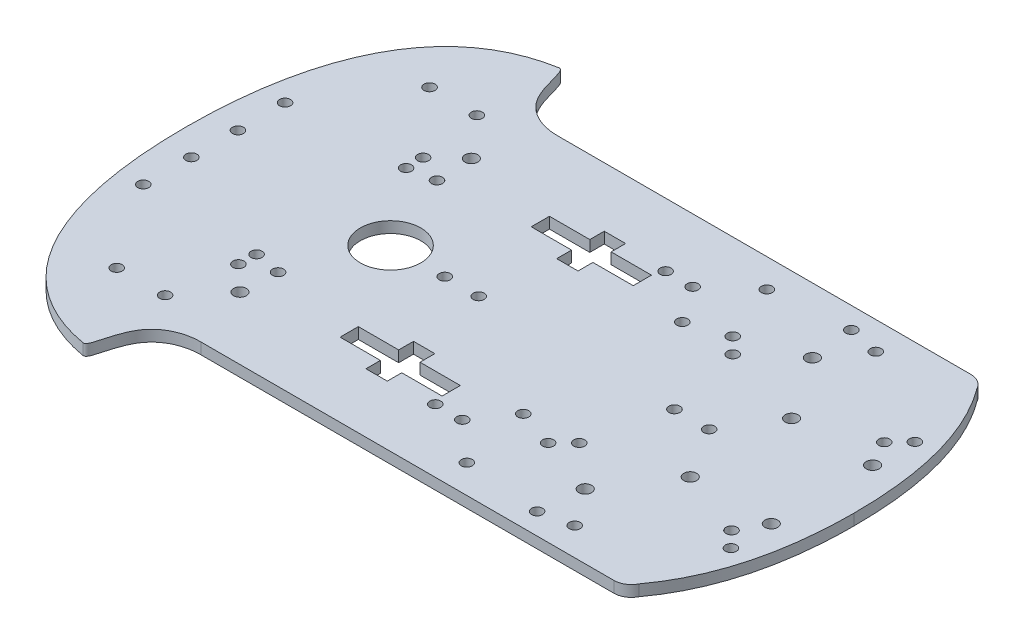
from build123d import *

# Parameters (mm, degrees)
SKETCH3_R           = 1.63195
SKETCH3_R_2         = 1.89865
SKETCH3_R_3         = 8.962636394
BOSS_EXTRUDE1_DEPTH = 3.3


with BuildPart() as part:
    # Sketch3 → Boss-Extrude1 (new body)
    with BuildSketch(Plane(origin=(0, 0, 0), x_dir=(1, 0, 0), z_dir=(0, 1, 0))):
        with BuildLine():
            Line((-19.412747253, 52.829242203), (102.905008148, 52.829242203))
            ThreePointArc((102.905008148, 52.829242203), (105.595648402, 52.072632384), (107.497615337, 50.024578386))
            add(Edge.make_bspline(
                [(107.497615337, 50.024578386), (121.191162078, 31.512548829), (121.191162078, 0)],
                knots=[0, 0, 0, 1, 1, 1], degree=2))
            add(Edge.make_bspline(
                [(107.497615337, -50.024578386), (121.191162078, -31.512548829), (121.191162078, 0)],
                knots=[0, 0, 0, 1, 1, 1], degree=2))
            ThreePointArc((107.497615337, -50.024578386), (105.595648402, -52.072632384), (102.905008148, -52.829242203))
            Line((102.905008148, -52.829242203), (-19.412747253, -52.829242203))
            add(Edge.make_bspline(
                [(-36.650707215, -70.466749861), (-34.711426836, -70.808051725), (-34.724909533, -61.825831762), (-27.646820994, -54.443797364), (-23.250799114, -52.829242203), (-19.412747253, -52.829242203)],
                knots=[0, 0, 0, 0, 0.592102183, 0.692102183, 1, 1, 1, 1], degree=3))
            add(Edge.make_bspline(
                [(-76.701202739, 0), (-76.701202739, -30.929666745), (-68.718634037, -64.822984621), (-36.650707215, -70.466749861)],
                knots=[0, 0, 0, 0, 1, 1, 1, 1], degree=3))
            add(Edge.make_bspline(
                [(-76.701202739, 0), (-76.701202739, 30.929666745), (-68.718634037, 64.822984621), (-36.650707215, 70.466749861)],
                knots=[0, 0, 0, 0, 1, 1, 1, 1], degree=3))
            add(Edge.make_bspline(
                [(-36.650707215, 70.466749861), (-34.711426836, 70.808051725), (-34.724909533, 61.825831762), (-27.646820994, 54.443797364), (-23.250799114, 52.829242203), (-19.412747253, 52.829242203)],
                knots=[0, 0, 0, 0, 0.592102183, 0.692102183, 1, 1, 1, 1], degree=3))
        make_face()
        with Locations((83.035807722, 44.56167379)):
            Circle(SKETCH3_R, mode=Mode.SUBTRACT)
        with Locations((83.035807722, -44.56167379)):
            Circle(SKETCH3_R, mode=Mode.SUBTRACT)
        with Locations((111.943040645, 27.227466133)):
            Circle(SKETCH3_R, mode=Mode.SUBTRACT)
        with Locations((111.943040645, -27.227466133)):
            Circle(SKETCH3_R, mode=Mode.SUBTRACT)
        with Locations((107.497615337, 22.610268935)):
            Circle(SKETCH3_R, mode=Mode.SUBTRACT)
        with Locations((107.497615337, -22.610268935)):
            Circle(SKETCH3_R, mode=Mode.SUBTRACT)
        with Locations((111.666224747, 15)):
            Circle(SKETCH3_R_2, mode=Mode.SUBTRACT)
        with Locations((111.666224747, -15)):
            Circle(SKETCH3_R_2, mode=Mode.SUBTRACT)
        with Locations((87.666224747, 15)):
            Circle(SKETCH3_R_2, mode=Mode.SUBTRACT)
        with Locations((87.666224747, -15)):
            Circle(SKETCH3_R_2, mode=Mode.SUBTRACT)
        with Locations((75.205099745, 33.627264799)):
            Circle(SKETCH3_R_2, mode=Mode.SUBTRACT)
        with Locations((75.205099745, -33.627264799)):
            Circle(SKETCH3_R_2, mode=Mode.SUBTRACT)
        with Locations((73.846750426, 46.522974557)):
            Circle(SKETCH3_R, mode=Mode.SUBTRACT)
        with Locations((73.846750426, -46.522974557)):
            Circle(SKETCH3_R, mode=Mode.SUBTRACT)
        with Locations((62.53353943, 22.717090363)):
            Circle(SKETCH3_R, mode=Mode.SUBTRACT)
        with Locations((62.53353943, -22.717090363)):
            Circle(SKETCH3_R, mode=Mode.SUBTRACT)
        with Locations((57.916606771, 27.334023022)):
            Circle(SKETCH3_R, mode=Mode.SUBTRACT)
        with Locations((57.916606771, -27.334023022)):
            Circle(SKETCH3_R, mode=Mode.SUBTRACT)
        with Locations((50.945704163, 44.414408656)):
            Circle(SKETCH3_R, mode=Mode.SUBTRACT)
        with Locations((50.945704163, -44.414408656)):
            Circle(SKETCH3_R, mode=Mode.SUBTRACT)
        with Locations((46.781864412, 23.53455238)):
            Circle(SKETCH3_R, mode=Mode.SUBTRACT)
        with Locations((46.781864412, -23.53455238)):
            Circle(SKETCH3_R, mode=Mode.SUBTRACT)
        with Locations((39.284916667, 34.098304181)):
            Circle(SKETCH3_R, mode=Mode.SUBTRACT)
        with Locations((39.284916667, -34.098304181)):
            Circle(SKETCH3_R, mode=Mode.SUBTRACT)
        with Locations((31.284916667, 34.098304181)):
            Circle(SKETCH3_R, mode=Mode.SUBTRACT)
        with Locations((31.284916667, -34.098304181)):
            Circle(SKETCH3_R, mode=Mode.SUBTRACT)
        with Locations((-26.375402413, 34.25317527)):
            Circle(SKETCH3_R_2, mode=Mode.SUBTRACT)
        with Locations((-26.375402413, -34.25317527)):
            Circle(SKETCH3_R_2, mode=Mode.SUBTRACT)
        with Locations((-25.829159842, 23.525142795)):
            Circle(SKETCH3_R, mode=Mode.SUBTRACT)
        with Locations((-25.829159842, -23.525142795)):
            Circle(SKETCH3_R, mode=Mode.SUBTRACT)
        with Locations((-33.59104133, 22.129151777)):
            Circle(SKETCH3_R, mode=Mode.SUBTRACT)
        with Locations((-33.59104133, -22.129151777)):
            Circle(SKETCH3_R, mode=Mode.SUBTRACT)
        with Locations((-36.650707215, 46.142478568)):
            Circle(SKETCH3_R, mode=Mode.SUBTRACT)
        with Locations((-36.650707215, -46.142478568)):
            Circle(SKETCH3_R, mode=Mode.SUBTRACT)
        with Locations((-50.818365766, 46.30222602)):
            Circle(SKETCH3_R, mode=Mode.SUBTRACT)
        with Locations((-50.818365766, -46.30222602)):
            Circle(SKETCH3_R, mode=Mode.SUBTRACT)
        with Locations((-68.273903527, 20.985394647)):
            Circle(SKETCH3_R, mode=Mode.SUBTRACT)
        with Locations((-68.273903527, -20.985394647)):
            Circle(SKETCH3_R, mode=Mode.SUBTRACT)
        with Locations((-68.129041774, 6.896821773)):
            Circle(SKETCH3_R, mode=Mode.SUBTRACT)
        with Locations((-68.129041774, -6.896821773)):
            Circle(SKETCH3_R, mode=Mode.SUBTRACT)
        with Locations((-16.053014444, 0)):
            Circle(SKETCH3_R_3, mode=Mode.SUBTRACT)
        with Locations((10.044832328, 0)):
            Circle(SKETCH3_R, mode=Mode.SUBTRACT)
        with Locations((68.000684971, 0)):
            Circle(SKETCH3_R, mode=Mode.SUBTRACT)
        with Locations((78.271931801, 0)):
            Circle(SKETCH3_R, mode=Mode.SUBTRACT)
        with Locations((-33.750207153, 27.334023022)):
            Circle(SKETCH3_R, mode=Mode.SUBTRACT)
        with Locations((-33.750207153, -27.334023022)):
            Circle(SKETCH3_R, mode=Mode.SUBTRACT)
        Circle(SKETCH3_R, mode=Mode.SUBTRACT)
        Polygon((11.94, 30.992945559), (0, 30.992945559), (0, 25.592945559), (11.94, 25.592945559), (11.94, 21.192394067), (18.26, 21.192394067), (18.26, 25.592945559), (30.2, 25.592945559), (30.2, 30.992945559), (18.26, 30.992945559), (18.26, 35.273941836), (11.94, 35.273941836), align=None, mode=Mode.SUBTRACT)
        Polygon((11.94, -30.992945559), (0, -30.992945559), (0, -25.592945559), (11.94, -25.592945559), (11.94, -21.192394067), (18.26, -21.192394067), (18.26, -25.592945559), (30.2, -25.592945559), (30.2, -30.992945559), (18.26, -30.992945559), (18.26, -35.273941836), (11.94, -35.273941836), align=None, mode=Mode.SUBTRACT)
    extrude(amount=BOSS_EXTRUDE1_DEPTH)


solid = part.part
